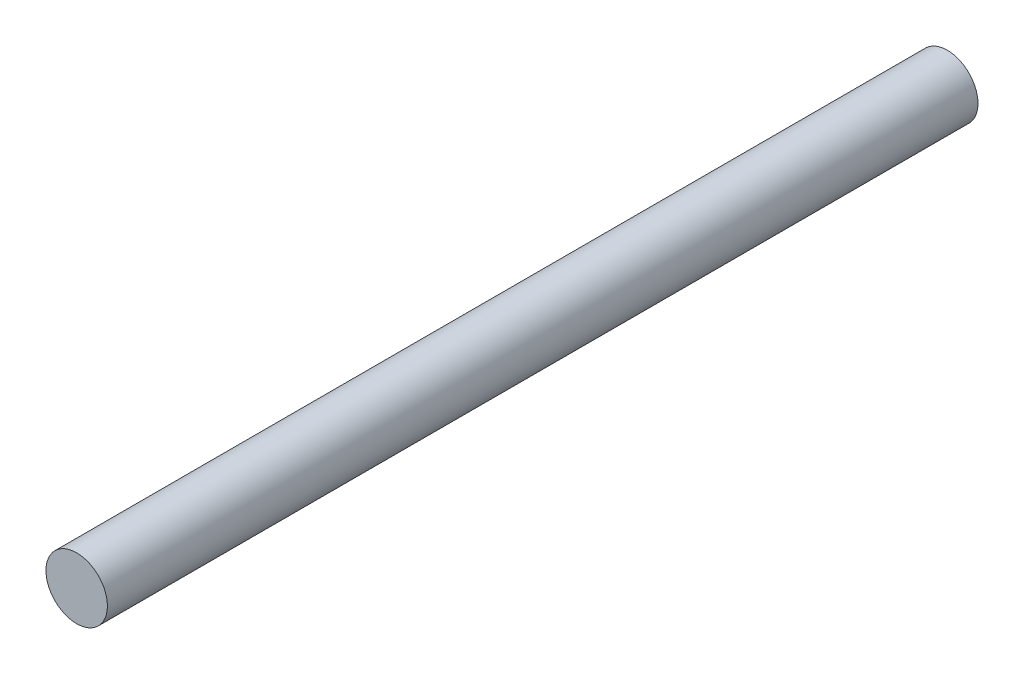
from build123d import *

# Parameters (mm, degrees)
CROQUIS1_R              = 6
SALIENTE_EXTRUIR1_DEPTH = 170


with BuildPart() as part:
    # Croquis1 → Saliente-Extruir1 (new body)
    with BuildSketch(Plane.XY):
        Circle(CROQUIS1_R)
    extrude(amount=SALIENTE_EXTRUIR1_DEPTH)


solid = part.part
